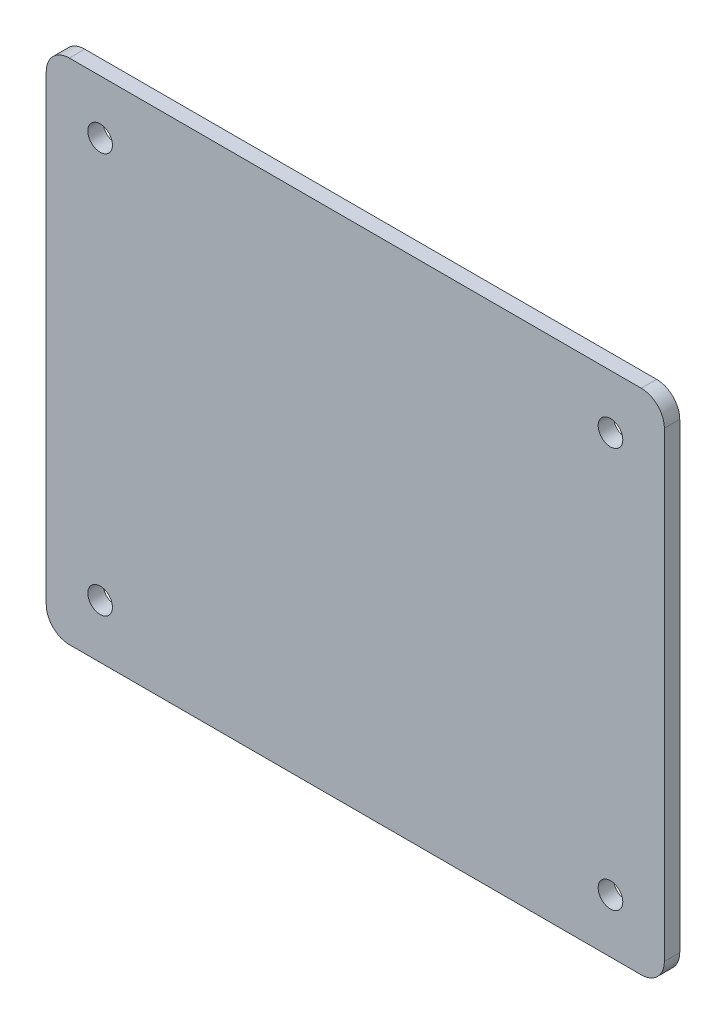
from build123d import *

# Parameters (mm, degrees)
SKETCH1_W                  = 80.3
SKETCH1_H                  = 66
BOSS_EXTRUDE1_DEPTH        = 2
F_3_2_3_2_DIAMETER_HOLE1_D = 3.2
FILLET1_R                  = 3


with BuildPart() as part:
    # Sketch1 → Boss-Extrude1 (new body)
    with BuildSketch(Plane.XY):
        with Locations((40.15, 33)):
            Rectangle(SKETCH1_W, SKETCH1_H)
    extrude(amount=BOSS_EXTRUDE1_DEPTH)

    # Ø3.2 (3.2) Diameter Hole1 (through all)
    with Locations(Plane.XY.offset(2)):
        with Locations((7, 59), (73.3, 59), (73.3, 7), (7, 7)):
            Hole(F_3_2_3_2_DIAMETER_HOLE1_D / 2)

    # Fillet1
    fillet1_edges = [part.edges().sort_by_distance(p)[0] for p in [
        (0, 66, 1),
        (80.3, 66, 1),
        (80.3, 0, 1),
        (0, 0, 1),
    ]]
    fillet(fillet1_edges, radius=FILLET1_R)


solid = part.part
